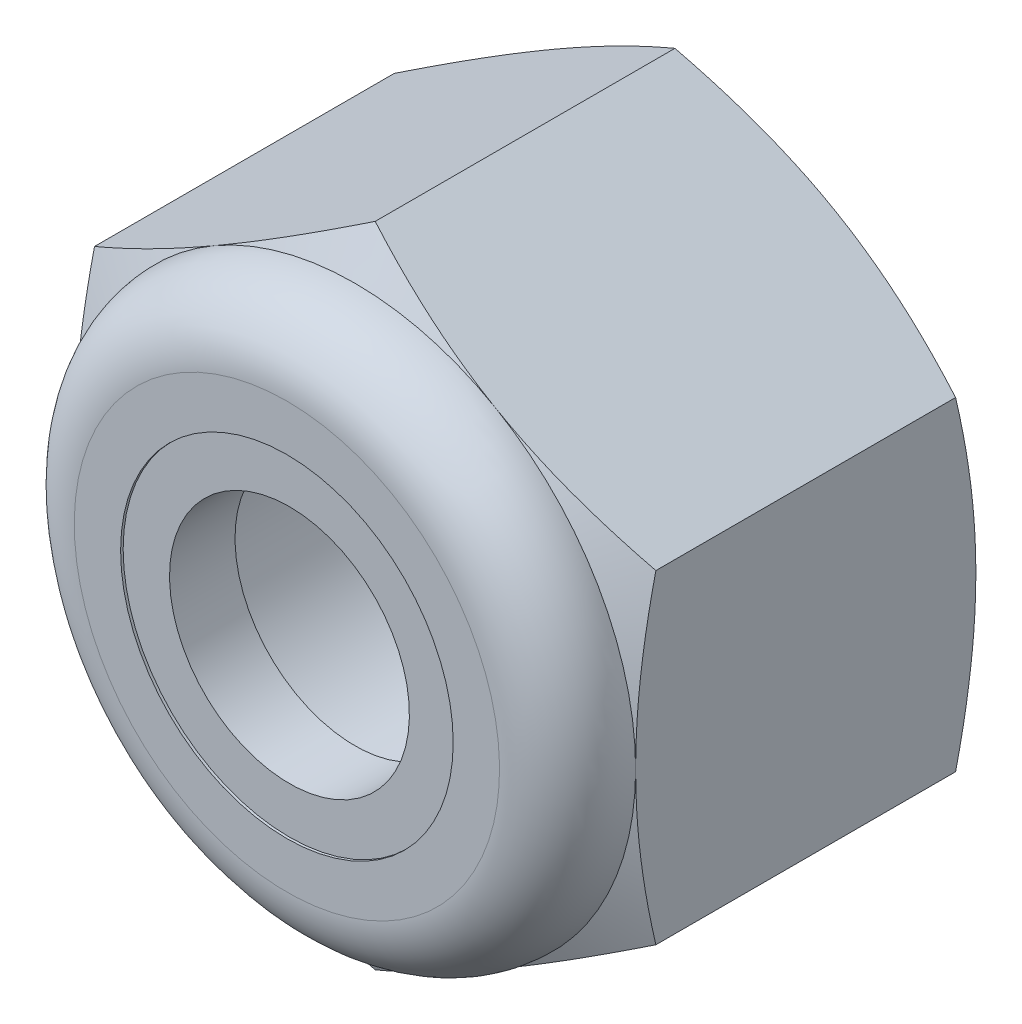
from build123d import *

# Parameters (mm, degrees)
SKETCH3_R           = 1.5
BOSS_EXTRUDE1_DEPTH = 2


with BuildPart() as part:
    # Sketch3 → Boss-Extrude1 (new, symmetric)
    with BuildSketch(Plane.XY):
        Polygon((0, -3.175426481), (2.75, -1.58771324), (2.75, 1.58771324), (0, 3.175426481), (-2.75, 1.58771324), (-2.75, -1.58771324), align=None)
        Circle(SKETCH3_R, mode=Mode.SUBTRACT)
    extrude(amount=BOSS_EXTRUDE1_DEPTH, both=True)

    # Sketch4 → Cut-Revolve1 (revolve, cut)
    with BuildSketch(Plane(origin=(0, 0, 0), x_dir=(0, 0, -1), z_dir=(1, 0, 0))):
        with BuildLine():
            Line((3.27, 4.445426481), (-3.27, 4.445426481))
            Line((-3.27, 4.445426481), (-3.27, 2.083333333))
            Line((-3.27, 2.083333333), (-2, 2.083333333))
            ThreePointArc((-2, 2.083333333), (-1.804737854, 2.554737854), (-1.333333333, 2.75))
            Line((-1.333333333, 2.75), (-1.134953707, 3.175426481))
            Line((-1.134953707, 3.175426481), (1.801620374, 3.175426481))
            Line((1.801620374, 3.175426481), (2, 2.75))
            Line((2, 2.75), (2, 0))
            Line((2, 0), (3.27, 0))
            Line((3.27, 0), (3.27, 4.445426481))
        make_face()
        with BuildLine():
            Line((-3.27, 1.629286903), (-3.27, 0))
            Line((-3.27, 0), (-1.333333333, 0))
            Line((-1.333333333, 0), (-1.333333333, 2.725))
            ThreePointArc((-1.333333333, 2.725), (-1.787060185, 2.537060185), (-1.975, 2.083333333))
            Line((-1.975, 2.083333333), (-1.975, 1.629286903))
            Line((-1.975, 1.629286903), (-3.27, 1.629286903))
        make_face()
    revolve(axis=Axis((0, 0, -2), (0, 0, 1)), mode=Mode.SUBTRACT)


with BuildPart() as body_2:
    # Sketch5 → Revolve1 (revolve)
    with BuildSketch(Plane(origin=(0, 0, 0), x_dir=(0, 0, -1), z_dir=(1, 0, 0))):
        with BuildLine():
            Line((-1.975, 2.083333333), (-1.975, 1.175240474))
            Line((-1.975, 1.175240474), (-1.333333333, 1.175240474))
            Line((-1.333333333, 1.175240474), (-1.333333333, 2.725))
            ThreePointArc((-1.333333333, 2.725), (-1.787060185, 2.537060185), (-1.975, 2.083333333))
        make_face()
    revolve(axis=Axis((0, 0, -2), (0, 0, 1)))


solid = Compound([part.part, body_2.part])
